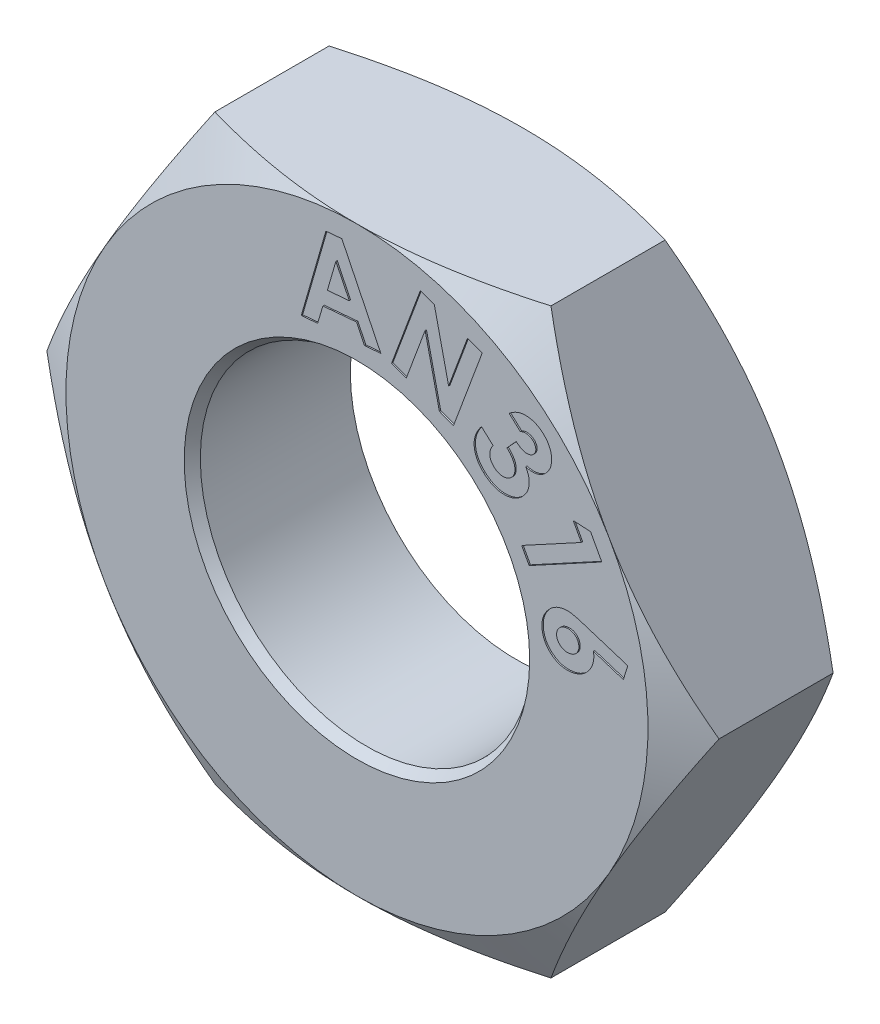
from build123d import *

# Parameters (mm, degrees)
SKETCH2_R             = 3.175
NUT_DEPTH             = 3.175
SKETCH3_OUTSIDE_W     = 29.302
SKETCH3_OUTSIDE_H     = 27.582
SKETCH3_OUTSIDE_R     = 5.5626
CUT_EXTRUDE1_DEPTH    = 3.175
CUT_EXTRUDE1_TAPER    = 60
SKETCH4_OUTSIDE_W     = 29.302
SKETCH4_OUTSIDE_H     = 27.582
SKETCH4_OUTSIDE_R     = 5.5626
CUT_EXTRUDE2_DEPTH    = 3.175
CUT_EXTRUDE2_TAPER    = 60
CHAMFER1_SIZE         = 0.127
CHAMFER1_SIZE2        = 0.181374797
CHAMFER1_PART_2_SIZE  = 0.127
CHAMFER1_PART_2_SIZE2 = 0.181374797
CUT_EXTRUDE3_DEPTH    = 0.0254


with BuildPart() as part:
    # Sketch2 → Nut (new body)
    with BuildSketch(Plane.XY):
        Polygon((3.211568607, -5.5626), (6.423137215, 0), (3.211568607, 5.5626), (-3.211568607, 5.5626), (-6.423137215, 0), (-3.211568607, -5.5626), align=None)
        Circle(SKETCH2_R, mode=Mode.SUBTRACT)
    extrude(amount=NUT_DEPTH)

    # Sketch3 outside → Cut-Extrude1 (cut)
    with BuildSketch(Plane.XY.offset(3.175)):
        Rectangle(SKETCH3_OUTSIDE_W, SKETCH3_OUTSIDE_H)
        Circle(SKETCH3_OUTSIDE_R, mode=Mode.SUBTRACT)
    extrude(amount=-CUT_EXTRUDE1_DEPTH, taper=CUT_EXTRUDE1_TAPER, mode=Mode.SUBTRACT)

    # Sketch4 outside → Cut-Extrude2 (cut)
    with BuildSketch(Plane(origin=(0, 0, 0), x_dir=(-1, 0, 0), z_dir=(0, 0, -1))):
        Rectangle(SKETCH4_OUTSIDE_W, SKETCH4_OUTSIDE_H)
        Circle(SKETCH4_OUTSIDE_R, mode=Mode.SUBTRACT)
    extrude(amount=-CUT_EXTRUDE2_DEPTH, taper=CUT_EXTRUDE2_TAPER, mode=Mode.SUBTRACT)

    # Chamfer1
    chamfer1_edges = [part.edges().sort_by_distance(p)[0] for p in [
        (-3.175, 0, 0),
    ]]
    chamfer1_side = [part.faces().sort_by_distance(p)[0] for p in [
        (-3.175, 0, 1.5875),
    ]]
    chamfer(chamfer1_edges, length=CHAMFER1_SIZE, length2=CHAMFER1_SIZE2, reference=chamfer1_side[0])

    # Chamfer1 part 2
    chamfer1_part_2_edges = [part.edges().sort_by_distance(p)[0] for p in [
        (-3.175, 0, 3.175),
    ]]
    chamfer1_part_2_side = [part.faces().sort_by_distance(p)[0] for p in [
        (2.702632941, -4.681097603, 3.175),
    ]]
    chamfer(chamfer1_part_2_edges, length=CHAMFER1_PART_2_SIZE, length2=CHAMFER1_PART_2_SIZE2, reference=chamfer1_part_2_side[0])

    # Sketch5 → Cut-Extrude3 (cut)
    with BuildSketch(Plane.XY.offset(3.175)):
        with BuildLine():
            Line((5.175926913, 0.8373015), (5.092608604, 0.566039981))
            Line((5.092608604, 0.566039981), (4.520828756, 0.74857704))
            add(Edge.make_bspline(
                [(4.520828756, 0.74857704), (4.523031089, 0.732388227), (4.527378546, 0.700431133), (4.528722802, 0.652566624), (4.524762683, 0.605917776), (4.516491286, 0.56029552), (4.503461501, 0.515705854), (4.485440185, 0.472334157), (4.463075671, 0.429923664), (4.435794943, 0.389481994), (4.405346105, 0.351118696), (4.371344021, 0.316488213), (4.334452526, 0.285918755), (4.294574931, 0.25943147), (4.252320946, 0.236240212), (4.206644296, 0.217920939), (4.158335256, 0.203149278), (4.124767327, 0.196637606), (4.107735307, 0.193333651)],
                knots=[0, 0, 0, 0, 4.8991e-05, 9.6709e-05, 0.000143295, 0.000189203, 0.000235594, 0.000282366, 0.000329881, 0.000379184, 0.000428501, 0.000476625, 0.000524508, 0.00057196, 0.000620055, 0.000668834, 0.000719336, 0.000771354, 0.000771354, 0.000771354, 0.000771354], degree=3))
            add(Edge.make_bspline(
                [(4.107735307, 0.193333651), (4.091123186, 0.191024396), (4.058325879, 0.186465234), (4.009309963, 0.184828182), (3.961461398, 0.188365099), (3.914843339, 0.196772113), (3.869266938, 0.209365734), (3.824909871, 0.227071608), (3.782037794, 0.249842924), (3.74058247, 0.276690646), (3.701824254, 0.307240783), (3.666625439, 0.340731062), (3.635597723, 0.376830824), (3.608711728, 0.415499072), (3.586021999, 0.456902098), (3.56722938, 0.500727309), (3.552793602, 0.547242217), (3.546476379, 0.579327716), (3.543269662, 0.595614801)],
                knots=[0, 0, 0, 0, 5.0292e-05, 9.9291e-05, 0.000146803, 0.000193963, 0.000241184, 0.000288426, 0.000336932, 0.000386593, 0.000436408, 0.000484767, 0.000532126, 0.000578968, 0.000625794, 0.000673522, 0.000721803, 0.000771577, 0.000771577, 0.000771577, 0.000771577], degree=3))
            add(Edge.make_bspline(
                [(3.543269662, 0.595614801), (3.540785888, 0.612859646), (3.535911687, 0.646701242), (3.534917578, 0.697330178), (3.538171084, 0.746465919), (3.546886628, 0.794099259), (3.560346805, 0.840228403), (3.578563177, 0.885041896), (3.601885644, 0.928441221), (3.630082836, 0.969683057), (3.661740415, 1.008050362), (3.695269073, 1.04338108), (3.731572681, 1.073900166), (3.769336661, 1.100867551), (3.809460884, 1.123312346), (3.851734026, 1.141356775), (3.895914063, 1.156057787), (3.926597629, 1.161905253), (3.942052715, 1.164850578)],
                knots=[0, 0, 0, 0, 5.2224e-05, 0.000102486, 0.000151584, 0.000199739, 0.00024744, 0.00029551, 0.000344596, 0.00039496, 0.000445125, 0.000493704, 0.000540856, 0.000587178, 0.000632737, 0.000678461, 0.000724923, 0.000772076, 0.000772076, 0.000772076, 0.000772076], degree=3))
            add(Edge.make_bspline(
                [(3.942052715, 1.164850578), (3.954009103, 1.166652697), (3.978148843, 1.170291144), (4.01496713, 1.171867486), (4.05237667, 1.171428184), (4.084171181, 1.168251603), (4.111332047, 1.164598528), (4.134509801, 1.15994209), (4.160490934, 1.154250033), (4.189163731, 1.147303508), (4.22045411, 1.138480682), (4.254619721, 1.128733678), (4.291563859, 1.117654993), (4.316897103, 1.109361945), (4.330023468, 1.105064921)],
                knots=[0, 0, 0, 0, 3.625e-05, 7.3189e-05, 0.000110401, 0.000148405, 0.000168958, 0.000192596, 0.000219294, 0.000248757, 0.000281083, 0.000316815, 0.000355346, 0.00039678, 0.00039678, 0.00039678, 0.00039678], degree=3))
            Line((4.330023468, 1.105064921), (5.175926913, 0.8373015))
        make_face()
        with BuildLine():
            add(Edge.make_bspline(
                [(4.238754938, 0.718684212), (4.23579283, 0.7317914), (4.230000721, 0.757421205), (4.212220023, 0.792601002), (4.187583533, 0.823026253), (4.156572841, 0.847964811), (4.121163721, 0.867164432), (4.08209414, 0.878639786), (4.040383127, 0.883176017), (4.012207238, 0.879553327), (3.997704257, 0.877688619)],
                knots=[0, 0, 0, 0, 4.0191e-05, 7.859e-05, 0.000117031, 0.000156814, 0.00019722, 0.000237061, 0.000278292, 0.000322026, 0.000322026, 0.000322026, 0.000322026], degree=3))
            add(Edge.make_bspline(
                [(3.997704257, 0.877688619), (3.983437302, 0.874632347), (3.955640116, 0.868677624), (3.917242782, 0.850584676), (3.883746442, 0.825822343), (3.85596151, 0.794918984), (3.834464893, 0.760432203), (3.820359836, 0.723778744), (3.81402463, 0.685618967), (3.816894872, 0.660274945), (3.818347286, 0.647450237)],
                knots=[0, 0, 0, 0, 4.3655e-05, 8.5056e-05, 0.000126207, 0.000167857, 0.000208982, 0.000247431, 0.000285076, 0.000323639, 0.000323639, 0.000323639, 0.000323639], degree=3))
            add(Edge.make_bspline(
                [(3.818347286, 0.647450237), (3.821342915, 0.634360115), (3.827243049, 0.608578065), (3.844798696, 0.572793405), (3.870132603, 0.541763), (3.901304173, 0.515313587), (3.93749395, 0.49480528), (3.977339963, 0.4823028), (4.019980246, 0.477573975), (4.048709211, 0.480969653), (4.063532081, 0.482721672)],
                knots=[0, 0, 0, 0, 4.0191e-05, 7.916e-05, 0.000118296, 0.000159584, 0.00020116, 0.000242194, 0.00028409, 0.000328749, 0.000328749, 0.000328749, 0.000328749], degree=3))
            add(Edge.make_bspline(
                [(4.063532081, 0.482721672), (4.077787443, 0.485805739), (4.1055185, 0.491805197), (4.143769872, 0.509351685), (4.176953918, 0.533643282), (4.204087293, 0.564311173), (4.225180127, 0.599054444), (4.238583633, 0.637019414), (4.243577733, 0.677545028), (4.240393373, 0.704708113), (4.238754938, 0.718684212)],
                knots=[0, 0, 0, 0, 4.3655e-05, 8.4923e-05, 0.000125185, 0.000166172, 0.000206967, 0.000246392, 0.000286113, 0.00032821, 0.00032821, 0.00032821, 0.00032821], degree=3))
        make_face(mode=Mode.SUBTRACT)
        Polygon((4.465093309, 2.701644371), (4.679749259, 2.306041406), (3.291004767, 1.552042508), (3.148536819, 1.814399779), (4.288916426, 2.43356294), (4.133728125, 2.719452864), align=None)
        with BuildLine():
            Line((3.123685194, 3.685231693), (2.909665262, 3.881443131))
            add(Edge.make_bspline(
                [(2.909665262, 3.881443131), (2.92086422, 3.890642671), (2.942860008, 3.908711417), (2.977730998, 3.932118241), (3.012744911, 3.9525924), (3.048063653, 3.969922556), (3.083959016, 3.983652124), (3.120198699, 3.994220419), (3.156945959, 4.00134142), (3.181641842, 4.003456909), (3.193965142, 4.004512542)],
                knots=[0, 0, 0, 0, 4.3457e-05, 8.5353e-05, 0.000125824, 0.000165079, 0.00020323, 0.000240972, 0.000278206, 0.000315292, 0.000315292, 0.000315292, 0.000315292], degree=3))
            add(Edge.make_bspline(
                [(3.193965142, 4.004512542), (3.211037456, 4.005092564), (3.244717088, 4.00623681), (3.294619081, 4.001556401), (3.343027635, 3.99204319), (3.389952813, 3.977202296), (3.435664425, 3.957836116), (3.479726601, 3.93311068), (3.522271388, 3.903400104), (3.548744483, 3.880419803), (3.562219348, 3.868722778)],
                knots=[0, 0, 0, 0, 5.1203e-05, 0.000101012, 0.00014997, 0.000198953, 0.000248393, 0.000298647, 0.000350257, 0.000403759, 0.000403759, 0.000403759, 0.000403759], degree=3))
            add(Edge.make_bspline(
                [(3.562219348, 3.868722778), (3.573773602, 3.857690653), (3.596486195, 3.836004426), (3.626421417, 3.80045701), (3.652295748, 3.763523932), (3.67413056, 3.724982232), (3.692060947, 3.685015774), (3.705296432, 3.643341056), (3.71506027, 3.600389162), (3.720288815, 3.55637153), (3.721512417, 3.512424269), (3.719160296, 3.469594226), (3.71238915, 3.428494645), (3.702009179, 3.389080353), (3.687109408, 3.351497843), (3.668366238, 3.315512723), (3.645421772, 3.28126087), (3.627322072, 3.260402721), (3.6181889, 3.249877626)],
                knots=[0, 0, 0, 0, 4.7897e-05, 9.4153e-05, 0.000139145, 0.000183007, 0.000226856, 0.000270301, 0.000313969, 0.000358817, 0.000403039, 0.000445728, 0.000487291, 0.000527789, 0.000567769, 0.000608307, 0.00064932, 0.000691096, 0.000691096, 0.000691096, 0.000691096], degree=3))
            add(Edge.make_bspline(
                [(3.6181889, 3.249877626), (3.606023388, 3.237615388), (3.581948784, 3.213349369), (3.539988529, 3.183956957), (3.494352058, 3.161095592), (3.445125208, 3.145235992), (3.393192941, 3.136342074), (3.338942631, 3.134832838), (3.282765996, 3.140859111), (3.245490914, 3.150494597), (3.226402041, 3.155429008)],
                knots=[0, 0, 0, 0, 5.1737e-05, 0.000102383, 0.00015287, 0.00020436, 0.000256955, 0.000310404, 0.000366699, 0.000425788, 0.000425788, 0.000425788, 0.000425788], degree=3))
            add(Edge.make_bspline(
                [(3.226402041, 3.155429008), (3.232473231, 3.144688863), (3.244426126, 3.123543783), (3.259800421, 3.090990726), (3.272198166, 3.058228525), (3.281864369, 3.025284808), (3.28852493, 2.992193039), (3.292425984, 2.958896563), (3.293243533, 2.925497357), (3.291796394, 2.892091059), (3.287260366, 2.859135357), (3.280300951, 2.826764377), (3.270457563, 2.795232176), (3.257542497, 2.764595032), (3.242308779, 2.734683194), (3.224439893, 2.705578883), (3.203639578, 2.677518437), (3.188152741, 2.659762778), (3.180290763, 2.65074902)],
                knots=[0, 0, 0, 0, 3.7004e-05, 7.2853e-05, 0.000107877, 0.000141993, 0.000175734, 0.000209026, 0.000242431, 0.000275859, 0.000309231, 0.000342103, 0.000375093, 0.000408166, 0.00044173, 0.00047571, 0.000510501, 0.000546374, 0.000546374, 0.000546374, 0.000546374], degree=3))
            add(Edge.make_bspline(
                [(3.180290763, 2.65074902), (3.168136342, 2.638187915), (3.144183764, 2.61343389), (3.104388053, 2.581306084), (3.062671447, 2.553640067), (3.018268808, 2.531331571), (2.971889735, 2.513395575), (2.923014761, 2.500652113), (2.872084245, 2.492803298), (2.819488436, 2.489616494), (2.766451959, 2.49151143), (2.713903599, 2.498467064), (2.662507177, 2.510895763), (2.612326285, 2.528968803), (2.56321401, 2.551904913), (2.515254392, 2.580180566), (2.468364163, 2.613531012), (2.439009405, 2.639247561), (2.424065803, 2.652339064)],
                knots=[0, 0, 0, 0, 5.2394e-05, 0.000103253, 0.000153087, 0.000202295, 0.000252023, 0.000302006, 0.000353504, 0.00040639, 0.000459849, 0.00051247, 0.00056515, 0.000618158, 0.00067222, 0.000727524, 0.000784972, 0.000844542, 0.000844542, 0.000844542, 0.000844542], degree=3))
            add(Edge.make_bspline(
                [(2.424065803, 2.652339064), (2.410485125, 2.665373275), (2.383882571, 2.690905379), (2.348569673, 2.732098564), (2.317847489, 2.774554435), (2.29299549, 2.818982338), (2.271850953, 2.864285845), (2.256275846, 2.911251781), (2.245773752, 2.959660411), (2.240026374, 3.009192529), (2.239402244, 3.059276925), (2.243866541, 3.109146074), (2.253482778, 3.158616749), (2.26855387, 3.207576322), (2.288693628, 3.256127124), (2.314133151, 3.303987847), (2.344319033, 3.351706298), (2.368032717, 3.381943849), (2.380180586, 3.397433716)],
                knots=[0, 0, 0, 0, 5.6442e-05, 0.000110561, 0.000162538, 0.000213382, 0.000263045, 0.000312321, 0.000361474, 0.000411412, 0.000461662, 0.00051147, 0.000561364, 0.000612568, 0.000664892, 0.000718805, 0.000775, 0.000834023, 0.000834023, 0.000834023, 0.000834023], degree=3))
            Line((2.380180586, 3.397433716), (2.600242686, 3.195816128))
            add(Edge.make_bspline(
                [(2.600242686, 3.195816128), (2.594835743, 3.187293706), (2.584269815, 3.170639692), (2.570633486, 3.145264316), (2.559386757, 3.120427243), (2.550727099, 3.096048936), (2.544320657, 3.072125707), (2.540078843, 3.048626606), (2.538433808, 3.025485829), (2.539732803, 2.995576542), (2.54710988, 2.95919598), (2.563784726, 2.917674288), (2.589611741, 2.879177913), (2.611714181, 2.856890941), (2.62313932, 2.845370415)],
                knots=[0, 0, 0, 0, 3.0271e-05, 5.9154e-05, 8.6341e-05, 0.00011199, 0.000136674, 0.000160567, 0.000183519, 0.000206118, 0.000250211, 0.000294147, 0.00033957, 0.000388174, 0.000388174, 0.000388174, 0.000388174], degree=3))
            add(Edge.make_bspline(
                [(2.62313932, 2.845370415), (2.629598784, 2.839611618), (2.64225407, 2.828329068), (2.662857083, 2.814060889), (2.683807394, 2.801790507), (2.705629369, 2.792260148), (2.727890163, 2.784932531), (2.750776669, 2.779768601), (2.774214315, 2.776854103), (2.798079551, 2.776668302), (2.821734613, 2.778452681), (2.844682301, 2.782731414), (2.866885034, 2.788558893), (2.887817622, 2.797417263), (2.908042665, 2.807724211), (2.926810751, 2.820838187), (2.94528156, 2.835308335), (2.956230185, 2.84681252), (2.961818707, 2.852684617)],
                knots=[0, 0, 0, 0, 2.5939e-05, 5.0819e-05, 7.5038e-05, 9.8673e-05, 0.000122105, 0.000145249, 0.000168955, 0.000192808, 0.000216735, 0.000240002, 0.000262761, 0.000285438, 0.000308055, 0.000330723, 0.000354016, 0.000378301, 0.000378301, 0.000378301, 0.000378301], degree=3))
            add(Edge.make_bspline(
                [(2.961818707, 2.852684617), (2.967652365, 2.859307517), (2.979193704, 2.872410299), (2.992592544, 2.894709826), (3.003991242, 2.917678803), (3.012337359, 2.941926856), (3.017274762, 2.967505583), (3.020014226, 2.994140839), (3.019029037, 3.022053213), (3.016043548, 3.050941055), (3.009616683, 3.080599309), (2.999768712, 3.110468851), (2.986155768, 3.140321876), (2.969092624, 3.170147463), (2.949245218, 3.200564959), (2.924936477, 3.230269949), (2.898070261, 3.260709382), (2.878008657, 3.280015059), (2.867688098, 3.289946737)],
                knots=[0, 0, 0, 0, 2.6425e-05, 5.228e-05, 7.7739e-05, 0.000103283, 0.000128915, 0.000155749, 0.000183423, 0.000212536, 0.000242787, 0.000274263, 0.000306714, 0.000341031, 0.000377282, 0.000415523, 0.000456062, 0.000499012, 0.000499012, 0.000499012, 0.000499012], degree=3))
            Line((2.867688098, 3.289946737), (3.042592946, 3.480752025))
            add(Edge.make_bspline(
                [(3.042592946, 3.480752025), (3.056259197, 3.47041822), (3.081840863, 3.451074514), (3.119355462, 3.426297894), (3.15324533, 3.407885451), (3.184127578, 3.395564793), (3.212801372, 3.388192108), (3.240426985, 3.385588033), (3.267400822, 3.385499177), (3.293519138, 3.390159882), (3.318203571, 3.398047427), (3.34094226, 3.408860594), (3.36152616, 3.422623228), (3.372973629, 3.434218142), (3.378728263, 3.440046897)],
                knots=[0, 0, 0, 0, 5.1392e-05, 9.6199e-05, 0.000134753, 0.000166878, 0.000195724, 0.000223223, 0.000249937, 0.000276391, 0.000302439, 0.000327473, 0.000351729, 0.000376249, 0.000376249, 0.000376249, 0.000376249], degree=3))
            add(Edge.make_bspline(
                [(3.378728263, 3.440046897), (3.385309669, 3.448086131), (3.398120769, 3.463734978), (3.411579013, 3.490753921), (3.418290656, 3.51980731), (3.418803983, 3.549991205), (3.413465555, 3.58031668), (3.401614769, 3.609588647), (3.383630778, 3.637308761), (3.367607033, 3.65318165), (3.359329725, 3.661381032)],
                knots=[0, 0, 0, 0, 3.1102e-05, 6.0541e-05, 8.9621e-05, 0.000119838, 0.000150529, 0.000181355, 0.000213991, 0.000248863, 0.000248863, 0.000248863, 0.000248863], degree=3))
            add(Edge.make_bspline(
                [(3.359329725, 3.661381032), (3.351164727, 3.668243983), (3.335102657, 3.681744683), (3.307405697, 3.696910447), (3.277498625, 3.707182822), (3.245906409, 3.712272816), (3.213876335, 3.713499084), (3.182392091, 3.709296148), (3.151964418, 3.700017956), (3.133196523, 3.69020485), (3.123685194, 3.685231693)],
                knots=[0, 0, 0, 0, 3.1936e-05, 6.2824e-05, 9.41e-05, 0.000126357, 0.00015849, 0.000189928, 0.000221211, 0.000253355, 0.000253355, 0.000253355, 0.000253355], degree=3))
        make_face()
        Polygon((1.211045094, 5.06344945), (1.480080551, 4.963276673), (1.752296096, 3.756433224), (2.113554109, 4.727950151), (2.3946739, 4.623325251), (1.845790687, 3.146810327), (1.575801204, 3.247301112), (1.30326765, 4.450964474), (0.943281673, 3.482309626), (0.662161881, 3.586934526), align=None)
        Polygon((-0.593672812, 5.146385754), (-0.288702359, 5.173098494), (0.456710301, 3.647292204), (0.144425645, 3.619943446), (-0.007264559, 3.934454163), (-0.651232407, 3.878166603), (-0.751723193, 3.541395269), (-1.064325857, 3.514046511), align=None)
        Polygon((-0.402549515, 4.740924516), (-0.565370028, 4.180910994), (-0.145916402, 4.217482008), align=None, mode=Mode.SUBTRACT)
    extrude(amount=-CUT_EXTRUDE3_DEPTH, mode=Mode.SUBTRACT)


solid = part.part
